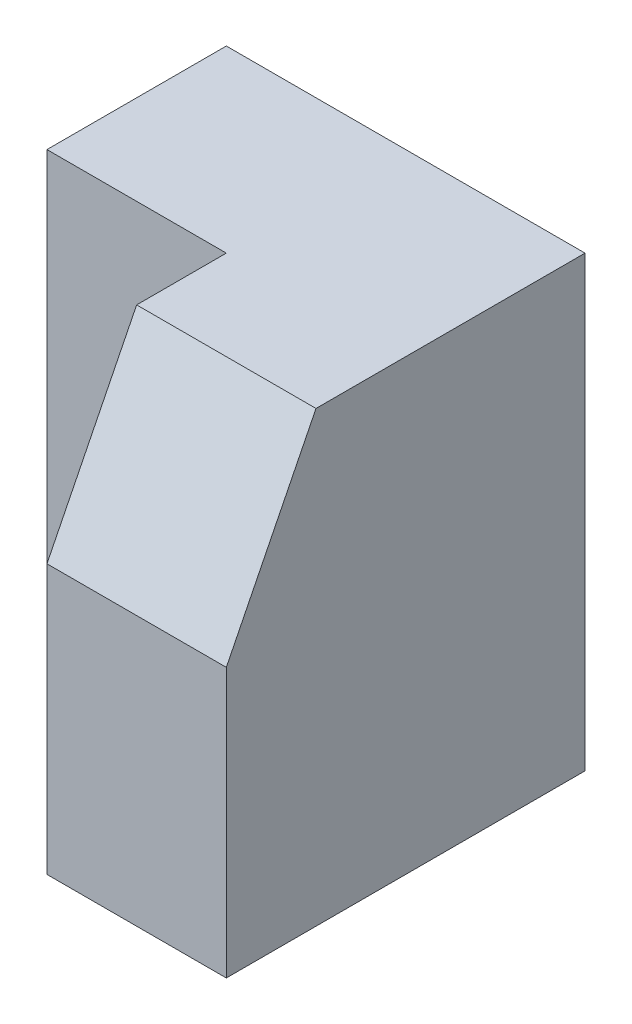
from build123d import *

# Parameters (mm, degrees)
SKETCH1_W           = 30
SKETCH1_H           = 25
BOSS_EXTRUDE1_DEPTH = 20
SKETCH2_W           = 20
SKETCH2_H           = 25
CUT_EXTRUDE1_DEPTH  = 10
CUT_EXTRUDE2_DEPTH  = 20
CUT_EXTRUDE3_DEPTH  = 40
SKETCH5_W           = 10
SKETCH5_H           = 10.001690502
CUT_EXTRUDE4_DEPTH  = 20


with BuildPart() as part:
    # Sketch1 → Boss-Extrude1 (new body)
    with BuildSketch(Plane.XY):
        with Locations((15, 12.5)):
            Rectangle(SKETCH1_W, SKETCH1_H)
    extrude(amount=BOSS_EXTRUDE1_DEPTH)

    # Sketch2 → Cut-Extrude1 (cut)
    with BuildSketch(Plane.XY.offset(20)):
        with Locations((10, 12.5)):
            Rectangle(SKETCH2_W, SKETCH2_H)
    extrude(amount=-CUT_EXTRUDE1_DEPTH, mode=Mode.SUBTRACT)

    # Sketch3 → Cut-Extrude2 (cut)
    with BuildSketch(Plane.ZY.offset(-20)):
        Polygon((15, 25), (20, 15), (20, 25), align=None)
    extrude(amount=-CUT_EXTRUDE2_DEPTH, mode=Mode.SUBTRACT)

    # Sketch4 → Cut-Extrude3 (cut)
    with BuildSketch(Plane(origin=(0, 25, 0), x_dir=(1, 0, 0), z_dir=(0, 1, 0))):
        Polygon((0, -10), (10, -10), (0, 0), align=None)
    extrude(amount=-CUT_EXTRUDE3_DEPTH, mode=Mode.SUBTRACT)

    # Sketch5 → Cut-Extrude4 (cut)
    with BuildSketch(Plane.XY.offset(10)):
        with Locations((5, 19.999154749)):
            Rectangle(SKETCH5_W, SKETCH5_H)
    extrude(amount=-CUT_EXTRUDE4_DEPTH, mode=Mode.SUBTRACT)


solid = part.part
